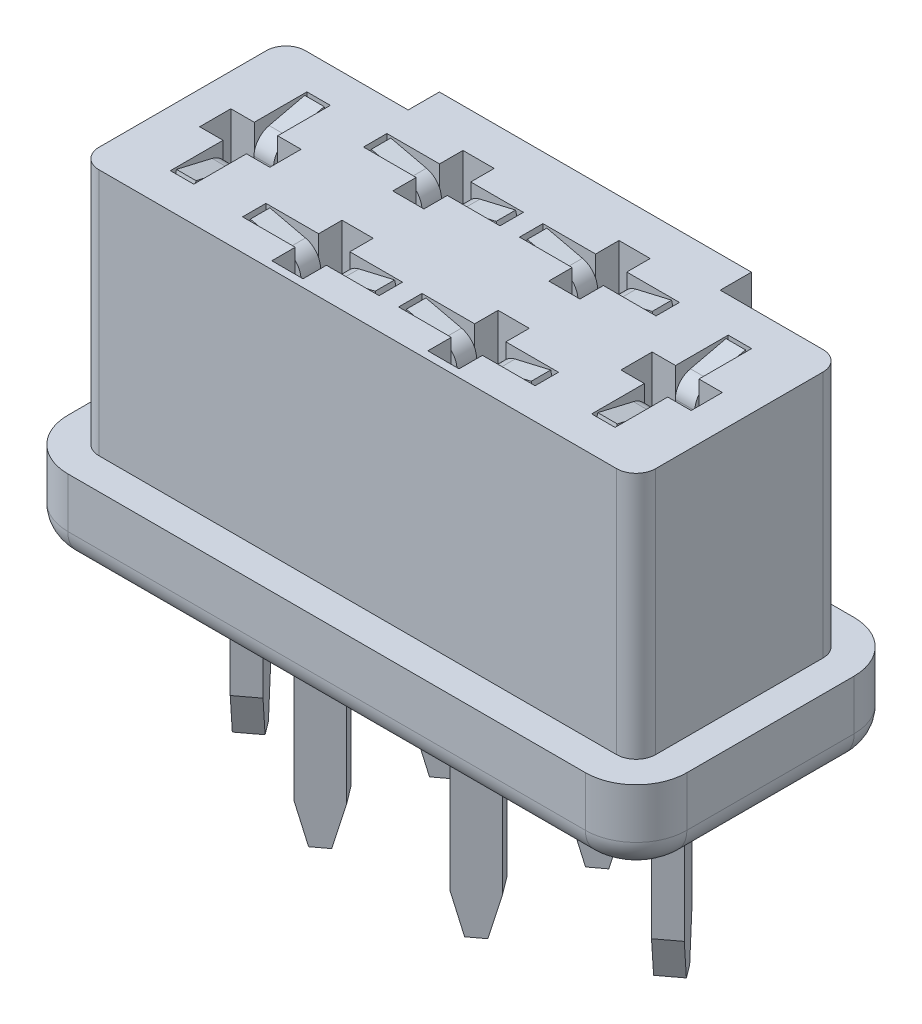
from build123d import *

# Parameters (mm, degrees)
SKETCH1_W              = 15.87
SKETCH1_H              = 6.89
BOSS_EXTRUDE1_DEPTH    = 8.38
FILLET1_R              = 1.3
FILLET2_R              = 0.75
SKETCH2_OUTSIDE_W      = 21.714
SKETCH2_OUTSIDE_H      = 12.734
CUT_EXTRUDE1_DEPTH     = 6.35
CUT_EXTRUDE2_DEPTH     = 3
BOSS_EXTRUDE2_DEPTH    = 4.69
CHAMFER1_SIZE          = 1
CHAMFER1_SIZE2         = 0.267949192
CHAMFER1_PART_2_SIZE   = 1
CHAMFER1_PART_2_SIZE2  = 0.267949192
CHAMFER1_PART_3_SIZE   = 1
CHAMFER1_PART_3_SIZE2  = 0.267949192
CHAMFER1_PART_4_SIZE   = 1
CHAMFER1_PART_4_SIZE2  = 0.267949192
CHAMFER1_PART_5_SIZE   = 1
CHAMFER1_PART_5_SIZE2  = 0.267949192
CHAMFER1_PART_6_SIZE   = 1
CHAMFER1_PART_6_SIZE2  = 0.267949192
CHAMFER1_PART_7_SIZE   = 1
CHAMFER1_PART_7_SIZE2  = 0.267949192
CHAMFER1_PART_8_SIZE   = 1
CHAMFER1_PART_8_SIZE2  = 0.267949192
CHAMFER1_PART_9_SIZE   = 1
CHAMFER1_PART_9_SIZE2  = 0.267949192
CHAMFER1_PART_10_SIZE  = 1
CHAMFER1_PART_10_SIZE2 = 0.267949192
CHAMFER1_PART_11_SIZE  = 1
CHAMFER1_PART_11_SIZE2 = 0.267949192
CHAMFER1_PART_12_SIZE  = 1
CHAMFER1_PART_12_SIZE2 = 0.267949192
BOSS_EXTRUDE3_DEPTH    = 0.25
MIRROR2_COPY_1_DEPTH   = 0.25
BOSS_EXTRUDE4_DEPTH    = 0.25
SKETCH8_W              = 0.769230769
SKETCH8_H              = 0.205128205
BOSS_EXTRUDE5_DEPTH    = 0.15


with BuildPart() as part:
    # Sketch1 → Boss-Extrude1 (new body)
    with BuildSketch(Plane(origin=(0, 0, 0), x_dir=(1, 0, 0), z_dir=(0, 1, 0))):
        Rectangle(SKETCH1_W, SKETCH1_H)
    extrude(amount=BOSS_EXTRUDE1_DEPTH)

    # Fillet1
    fillet1_edges = [part.edges().sort_by_distance(p)[0] for p in [
        (7.935, 4.19, 3.445),
        (-7.935, 4.19, 3.445),
        (-7.935, 4.19, -3.445),
        (7.935, 4.19, -3.445),
    ]]
    fillet(fillet1_edges, radius=FILLET1_R)

    # Fillet2
    fillet2_edges = [part.edges().sort_by_distance(p)[0] for p in [
        (0, 0, 3.445),
        (7.935, 0, 0),
        (-7.935, 0, 0),
        (0, 0, -3.445),
        (7.554238816, 0, 3.064238816),
        (7.554238816, 0, -3.064238816),
        (-7.554238816, 0, -3.064238816),
        (-7.554238816, 0, 3.064238816),
    ]]
    fillet(fillet2_edges, radius=FILLET2_R)

    # Sketch2 outside → Cut-Extrude1 (cut)
    with BuildSketch(Plane(origin=(0, 8.38, 0), x_dir=(1, 0, 0), z_dir=(0, 1, 0))):
        Rectangle(SKETCH2_OUTSIDE_W, SKETCH2_OUTSIDE_H)
        with BuildLine():
            Line((4, 2.645), (4, 3.445))
            Line((4, 3.445), (-4, 3.445))
            Line((-4, 3.445), (-4, 2.645))
            Line((-4, 2.645), (-6.635, 2.645))
            ThreePointArc((-6.635, 2.645), (-6.988553391, 2.498553391), (-7.135, 2.145))
            Line((-7.135, 2.145), (-7.135, -2.145))
            ThreePointArc((-7.135, -2.145), (-6.988553391, -2.498553391), (-6.635, -2.645))
            Line((-6.635, -2.645), (6.635, -2.645))
            ThreePointArc((6.635, -2.645), (6.988553391, -2.498553391), (7.135, -2.145))
            Line((7.135, -2.145), (7.135, 2.145))
            ThreePointArc((7.135, 2.145), (6.988553391, 2.498553391), (6.635, 2.645))
            Line((6.635, 2.645), (4, 2.645))
        make_face(mode=Mode.SUBTRACT)
    extrude(amount=-CUT_EXTRUDE1_DEPTH, mode=Mode.SUBTRACT)

    # Sketch3 → Cut-Extrude2 (cut)
    with BuildSketch(Plane(origin=(0, 8.38, 0), x_dir=(1, 0, 0), z_dir=(0, 1, 0))):
        Polygon((-2.4, -0.65), (-2.4, -1.25), (-3.75, -1.25), (-3.75, -1.85), (-2.4, -1.85), (-2.4, -2.45), (-1.6, -2.45), (-1.6, -1.85), (-0.25, -1.85), (-0.25, -1.25), (-1.6, -1.25), (-1.6, -0.65), align=None)
        Polygon((1.6, -0.65), (2.4, -0.65), (2.4, -1.25), (3.75, -1.25), (3.75, -1.85), (2.4, -1.85), (2.4, -2.45), (1.6, -2.45), (1.6, -1.85), (0.25, -1.85), (0.25, -1.25), (1.6, -1.25), align=None)
        Polygon((2.4, 0.65), (2.4, 1.25), (3.75, 1.25), (3.75, 1.85), (2.4, 1.85), (2.4, 2.45), (1.6, 2.45), (1.6, 1.85), (0.25, 1.85), (0.25, 1.25), (1.6, 1.25), (1.6, 0.65), align=None)
        Polygon((-1.6, 0.65), (-2.4, 0.65), (-2.4, 1.25), (-3.75, 1.25), (-3.75, 1.85), (-2.4, 1.85), (-2.4, 2.45), (-1.6, 2.45), (-1.6, 1.85), (-0.25, 1.85), (-0.25, 1.25), (-1.6, 1.25), align=None)
        Polygon((-5.7, 1.75), (-5.1, 1.75), (-5.1, 0.4), (-4.5, 0.4), (-4.5, -0.4), (-5.1, -0.4), (-5.1, -1.75), (-5.7, -1.75), (-5.7, -0.4), (-6.3, -0.4), (-6.3, 0.4), (-5.7, 0.4), align=None)
        Polygon((5.7, 0.4), (5.7, 1.75), (5.1, 1.75), (5.1, 0.4), (4.5, 0.4), (4.5, -0.4), (5.1, -0.4), (5.1, -1.75), (5.7, -1.75), (5.7, -0.4), (6.3, -0.4), (6.3, 0.4), align=None)
    extrude(amount=-CUT_EXTRUDE2_DEPTH, mode=Mode.SUBTRACT)

    # Sketch5 → Boss-Extrude2 (add)
    with BuildSketch(Plane.XZ):
        Polygon((-5.928, -0.204), (-5.352, 0.564), (-4.872, 0.204), (-5.448, -0.564), align=None)
        Polygon((-2.204, -1.022), (-1.436, -1.598), (-1.796, -2.078), (-2.564, -1.502), align=None)
        Polygon((-2.204, 2.078), (-1.436, 1.502), (-1.796, 1.022), (-2.564, 1.598), align=None)
        Polygon((1.796, 2.078), (2.564, 1.502), (2.204, 1.022), (1.436, 1.598), align=None)
        Polygon((1.796, -1.022), (2.564, -1.598), (2.204, -2.078), (1.436, -1.502), align=None)
        Polygon((4.872, -0.204), (5.448, 0.564), (5.928, 0.204), (5.352, -0.564), align=None)
    extrude(amount=BOSS_EXTRUDE2_DEPTH)

    # Chamfer1
    chamfer1_edges = [part.edges().sort_by_distance(p)[0] for p in [
        (-5.688, -4.69, -0.384),
    ]]
    chamfer1_side = [part.faces().sort_by_distance(p)[0] for p in [
        (-5.688, -2.345, -0.384),
    ]]
    chamfer(chamfer1_edges, length=CHAMFER1_SIZE, length2=CHAMFER1_SIZE2, reference=chamfer1_side[0])

    # Chamfer1 part 2
    chamfer1_part_2_edges = [part.edges().sort_by_distance(p)[0] for p in [
        (-5.112, -4.69, 0.384),
    ]]
    chamfer1_part_2_side = [part.faces().sort_by_distance(p)[0] for p in [
        (-5.112, -2.345, 0.384),
    ]]
    chamfer(chamfer1_part_2_edges, length=CHAMFER1_PART_2_SIZE, length2=CHAMFER1_PART_2_SIZE2, reference=chamfer1_part_2_side[0])

    # Chamfer1 part 3
    chamfer1_part_3_edges = [part.edges().sort_by_distance(p)[0] for p in [
        (-2.384, -4.69, -1.262),
    ]]
    chamfer1_part_3_side = [part.faces().sort_by_distance(p)[0] for p in [
        (-2.384, -2.345, -1.262),
    ]]
    chamfer(chamfer1_part_3_edges, length=CHAMFER1_PART_3_SIZE, length2=CHAMFER1_PART_3_SIZE2, reference=chamfer1_part_3_side[0])

    # Chamfer1 part 4
    chamfer1_part_4_edges = [part.edges().sort_by_distance(p)[0] for p in [
        (-1.616, -4.69, -1.838),
    ]]
    chamfer1_part_4_side = [part.faces().sort_by_distance(p)[0] for p in [
        (-1.616, -2.345, -1.838),
    ]]
    chamfer(chamfer1_part_4_edges, length=CHAMFER1_PART_4_SIZE, length2=CHAMFER1_PART_4_SIZE2, reference=chamfer1_part_4_side[0])

    # Chamfer1 part 5
    chamfer1_part_5_edges = [part.edges().sort_by_distance(p)[0] for p in [
        (-2.384, -4.69, 1.838),
    ]]
    chamfer1_part_5_side = [part.faces().sort_by_distance(p)[0] for p in [
        (-2.384, -2.345, 1.838),
    ]]
    chamfer(chamfer1_part_5_edges, length=CHAMFER1_PART_5_SIZE, length2=CHAMFER1_PART_5_SIZE2, reference=chamfer1_part_5_side[0])

    # Chamfer1 part 6
    chamfer1_part_6_edges = [part.edges().sort_by_distance(p)[0] for p in [
        (-1.616, -4.69, 1.262),
    ]]
    chamfer1_part_6_side = [part.faces().sort_by_distance(p)[0] for p in [
        (-1.616, -2.345, 1.262),
    ]]
    chamfer(chamfer1_part_6_edges, length=CHAMFER1_PART_6_SIZE, length2=CHAMFER1_PART_6_SIZE2, reference=chamfer1_part_6_side[0])

    # Chamfer1 part 7
    chamfer1_part_7_edges = [part.edges().sort_by_distance(p)[0] for p in [
        (1.616, -4.69, 1.838),
    ]]
    chamfer1_part_7_side = [part.faces().sort_by_distance(p)[0] for p in [
        (1.616, -2.345, 1.838),
    ]]
    chamfer(chamfer1_part_7_edges, length=CHAMFER1_PART_7_SIZE, length2=CHAMFER1_PART_7_SIZE2, reference=chamfer1_part_7_side[0])

    # Chamfer1 part 8
    chamfer1_part_8_edges = [part.edges().sort_by_distance(p)[0] for p in [
        (2.384, -4.69, 1.262),
    ]]
    chamfer1_part_8_side = [part.faces().sort_by_distance(p)[0] for p in [
        (2.384, -2.345, 1.262),
    ]]
    chamfer(chamfer1_part_8_edges, length=CHAMFER1_PART_8_SIZE, length2=CHAMFER1_PART_8_SIZE2, reference=chamfer1_part_8_side[0])

    # Chamfer1 part 9
    chamfer1_part_9_edges = [part.edges().sort_by_distance(p)[0] for p in [
        (1.616, -4.69, -1.262),
    ]]
    chamfer1_part_9_side = [part.faces().sort_by_distance(p)[0] for p in [
        (1.616, -2.345, -1.262),
    ]]
    chamfer(chamfer1_part_9_edges, length=CHAMFER1_PART_9_SIZE, length2=CHAMFER1_PART_9_SIZE2, reference=chamfer1_part_9_side[0])

    # Chamfer1 part 10
    chamfer1_part_10_edges = [part.edges().sort_by_distance(p)[0] for p in [
        (2.384, -4.69, -1.838),
    ]]
    chamfer1_part_10_side = [part.faces().sort_by_distance(p)[0] for p in [
        (2.384, -2.345, -1.838),
    ]]
    chamfer(chamfer1_part_10_edges, length=CHAMFER1_PART_10_SIZE, length2=CHAMFER1_PART_10_SIZE2, reference=chamfer1_part_10_side[0])

    # Chamfer1 part 11
    chamfer1_part_11_edges = [part.edges().sort_by_distance(p)[0] for p in [
        (5.112, -4.69, -0.384),
    ]]
    chamfer1_part_11_side = [part.faces().sort_by_distance(p)[0] for p in [
        (5.112, -2.345, -0.384),
    ]]
    chamfer(chamfer1_part_11_edges, length=CHAMFER1_PART_11_SIZE, length2=CHAMFER1_PART_11_SIZE2, reference=chamfer1_part_11_side[0])

    # Chamfer1 part 12
    chamfer1_part_12_edges = [part.edges().sort_by_distance(p)[0] for p in [
        (5.688, -4.69, 0.384),
    ]]
    chamfer1_part_12_side = [part.faces().sort_by_distance(p)[0] for p in [
        (5.688, -2.345, 0.384),
    ]]
    chamfer(chamfer1_part_12_edges, length=CHAMFER1_PART_12_SIZE, length2=CHAMFER1_PART_12_SIZE2, reference=chamfer1_part_12_side[0])

    # Sketch6 → Boss-Extrude3 (add, symmetric)
    with BuildSketch(Plane(origin=(0, 0, -1.55), x_dir=(-1, 0, 0), z_dir=(0, 0, -1))):
        with BuildLine():
            Line((-2.3, 5.68), (-1.7, 5.68))
            Line((-1.7, 5.68), (-1.7, 7.68))
            ThreePointArc((-1.7, 7.68), (-1.591652135, 7.990819249), (-1.313565578, 8.166932089))
            Line((-1.313565578, 8.166932089), (-0.4, 8.38))
            Line((-0.4, 8.38), (-0.331860653, 8.087840746))
            Line((-0.331860653, 8.087840746), (-1.245426231, 7.874772836))
            ThreePointArc((-1.245426231, 7.874772836), (-1.356660854, 7.8043277), (-1.4, 7.68))
            Line((-1.4, 7.68), (-1.4, 5.38))
            Line((-1.4, 5.38), (-2.6, 5.38))
            Line((-2.6, 5.38), (-2.6, 7.68))
            ThreePointArc((-2.6, 7.68), (-2.643339146, 7.8043277), (-2.754573769, 7.874772836))
            Line((-2.754573769, 7.874772836), (-3.668139347, 8.087840746))
            Line((-3.668139347, 8.087840746), (-3.6, 8.38))
            Line((-3.6, 8.38), (-2.686434422, 8.166932089))
            ThreePointArc((-2.686434422, 8.166932089), (-2.408347865, 7.990819249), (-2.3, 7.68))
            Line((-2.3, 7.68), (-2.3, 5.68))
        make_face()
    boss_extrude3 = extrude(amount=BOSS_EXTRUDE3_DEPTH, both=True)

    # Mirror1: Boss-Extrude3 across plane
    add(boss_extrude3.mirror(Plane(origin=(0, 0, 0), x_dir=(0, 0, 1), z_dir=(1, 0, 0))))

    # Mirror2: Boss-Extrude3 across plane
    add(boss_extrude3.mirror(Plane.XY))

    # Mirror2 copy 1 sketch → Mirror2 copy 1 (add, symmetric)
    with BuildSketch(Plane.XY.offset(1.55)):
        with BuildLine():
            Line((-2.3, 5.68), (-1.7, 5.68))
            Line((-1.7, 5.68), (-1.7, 7.68))
            ThreePointArc((-1.7, 7.68), (-1.591652135, 7.990819249), (-1.313565578, 8.166932089))
            Line((-1.313565578, 8.166932089), (-0.4, 8.38))
            Line((-0.4, 8.38), (-0.331860653, 8.087840746))
            Line((-0.331860653, 8.087840746), (-1.245426231, 7.874772836))
            ThreePointArc((-1.245426231, 7.874772836), (-1.356660854, 7.8043277), (-1.4, 7.68))
            Line((-1.4, 7.68), (-1.4, 5.38))
            Line((-1.4, 5.38), (-2.6, 5.38))
            Line((-2.6, 5.38), (-2.6, 7.68))
            ThreePointArc((-2.6, 7.68), (-2.643339146, 7.8043277), (-2.754573769, 7.874772836))
            Line((-2.754573769, 7.874772836), (-3.668139347, 8.087840746))
            Line((-3.668139347, 8.087840746), (-3.6, 8.38))
            Line((-3.6, 8.38), (-2.686434422, 8.166932089))
            ThreePointArc((-2.686434422, 8.166932089), (-2.408347865, 7.990819249), (-2.3, 7.68))
            Line((-2.3, 7.68), (-2.3, 5.68))
        make_face()
    extrude(amount=MIRROR2_COPY_1_DEPTH, both=True)

    # Sketch7 → Boss-Extrude4 (add, symmetric)
    with BuildSketch(Plane.ZY.offset(5.4)):
        with BuildLine():
            Line((-0.34356411, 5.68), (0.34356411, 5.68))
            Line((0.34356411, 5.68), (0.34356411, 7.68))
            ThreePointArc((0.34356411, 7.68), (0.451911976, 7.990819249), (0.729998532, 8.166932089))
            Line((0.729998532, 8.166932089), (1.64356411, 8.38))
            Line((1.64356411, 8.38), (1.711703457, 8.087840746))
            Line((1.711703457, 8.087840746), (0.798137879, 7.874772836))
            ThreePointArc((0.798137879, 7.874772836), (0.686903256, 7.8043277), (0.64356411, 7.68))
            Line((0.64356411, 7.68), (0.64356411, 5.38))
            Line((0.64356411, 5.38), (-0.64356411, 5.38))
            Line((-0.64356411, 5.38), (-0.64356411, 7.68))
            ThreePointArc((-0.64356411, 7.68), (-0.686903256, 7.8043277), (-0.798137879, 7.874772836))
            Line((-0.798137879, 7.874772836), (-1.711703457, 8.087840746))
            Line((-1.711703457, 8.087840746), (-1.64356411, 8.38))
            Line((-1.64356411, 8.38), (-0.729998532, 8.166932089))
            ThreePointArc((-0.729998532, 8.166932089), (-0.451911976, 7.990819249), (-0.34356411, 7.68))
            Line((-0.34356411, 7.68), (-0.34356411, 5.68))
        make_face()
    boss_extrude4 = extrude(amount=BOSS_EXTRUDE4_DEPTH, both=True)

    # Mirror3: Boss-Extrude4 across plane
    add(boss_extrude4.mirror(Plane(origin=(0, 0, 0), x_dir=(0, 0, 1), z_dir=(1, 0, 0))))

    # Sketch8 → Boss-Extrude5 (add)
    with BuildSketch(Plane.XZ):
        with Locations((-5.483370513, 1.487427858)):
            Rectangle(SKETCH8_W, SKETCH8_H)
        Polygon((5.442706084, 1.533944278), (5.442706084, 1.976251971), (5.577321469, 1.976251971), (5.577321469, 1.533944278), (6.019629161, 1.533944278), (6.019629161, 1.399328894), (5.577321469, 1.399328894), (5.577321469, 0.957021201), (5.442706084, 0.957021201), (5.442706084, 1.399328894), (5.000398392, 1.399328894), (5.000398392, 1.533944278), align=None)
        Polygon((-0.685537905, 2.086538462), (0.814462095, 1.888521635), (0.814462095, 1.869290865), (-0.416307136, 1.25), (0.814462095, 0.632211538), (0.814462095, 0.612680288), (-0.685537905, 0.413461538), (-0.685537905, 0.548677885), (0.393789018, 0.692307692), (-0.685537905, 1.233774038), (-0.685537905, 1.264122596), (0.396192864, 1.807692308), (-0.685537905, 1.951021635), align=None)
        with BuildLine():
            Line((0.814462095, 0.105769231), (0.814462095, -0.188401442))
            add(Edge.make_bspline(
                [(0.814462095, -0.188401442), (0.814439854, -0.208634688), (0.814397239, -0.247402485), (0.813105205, -0.302994651), (0.81137948, -0.353484536), (0.80898724, -0.398763271), (0.80616013, -0.43897017), (0.80219497, -0.473923299), (0.798054843, -0.503897394), (0.793845669, -0.521857301), (0.791926037, -0.530048077)],
                knots=[0, 0, 0, 0, 6.0698e-05, 0.0001163, 0.000166813, 0.000212249, 0.000252326, 0.000287698, 0.000317785, 0.000343012, 0.000343012, 0.000343012, 0.000343012], degree=3))
            add(Edge.make_bspline(
                [(0.791926037, -0.530048077), (0.789088084, -0.540416759), (0.783479051, -0.560909797), (0.772244232, -0.590438462), (0.758924663, -0.618534282), (0.743737948, -0.645285804), (0.72606272, -0.670393235), (0.7064581, -0.694177969), (0.684934872, -0.716776426), (0.661075793, -0.737420944), (0.635760539, -0.756426873), (0.608425328, -0.772731078), (0.579665098, -0.786522282), (0.549185311, -0.797785496), (0.517171213, -0.806349883), (0.483529347, -0.812677522), (0.448375308, -0.816726024), (0.424349139, -0.817111475), (0.412118345, -0.817307692)],
                knots=[0, 0, 0, 0, 3.2236e-05, 6.3712e-05, 9.4626e-05, 0.000125448, 0.000155874, 0.000186614, 0.000217854, 0.000249372, 0.000281163, 0.000312701, 0.000344688, 0.000376727, 0.000410038, 0.000443983, 0.000479356, 0.000516034, 0.000516034, 0.000516034, 0.000516034], degree=3))
            add(Edge.make_bspline(
                [(0.412118345, -0.817307692), (0.399785012, -0.817127082), (0.375654013, -0.816773705), (0.34035139, -0.81253244), (0.306614937, -0.8068195), (0.274519458, -0.798035049), (0.244255557, -0.786529761), (0.215360743, -0.773033167), (0.188326598, -0.756754511), (0.163054976, -0.738049584), (0.139522156, -0.717241758), (0.117898673, -0.69441907), (0.098311099, -0.669673659), (0.080715524, -0.643084167), (0.065519975, -0.614391375), (0.051909702, -0.584030452), (0.040479247, -0.551737502), (0.034466364, -0.52939071), (0.031409211, -0.518028846)],
                knots=[0, 0, 0, 0, 3.6979e-05, 7.2351e-05, 0.000106537, 0.000139559, 0.000171984, 0.000203571, 0.000235108, 0.000266479, 0.000297771, 0.000329229, 0.00036067, 0.000392339, 0.000424738, 0.000457963, 0.000492081, 0.000527371, 0.000527371, 0.000527371, 0.000527371], degree=3))
            add(Edge.make_bspline(
                [(0.031409211, -0.518028846), (0.02941079, -0.508631417), (0.025031135, -0.488036406), (0.020141797, -0.454118096), (0.015968539, -0.414627216), (0.01283948, -0.369617668), (0.010160751, -0.319129851), (0.008031568, -0.263136455), (0.006861631, -0.201527565), (0.006801291, -0.158554175), (0.006769787, -0.136117788)],
                knots=[0, 0, 0, 0, 2.8816e-05, 6.3153e-05, 0.00010274, 0.000147933, 0.000198486, 0.000254415, 0.000316026, 0.000383334, 0.000383334, 0.000383334, 0.000383334], degree=3))
            Line((0.006769787, -0.136117788), (0.006769787, -0.028846154))
            Line((0.006769787, -0.028846154), (-0.685537905, -0.028846154))
            Line((-0.685537905, -0.028846154), (-0.685537905, 0.105769231))
            Line((-0.685537905, 0.105769231), (0.814462095, 0.105769231))
        make_face()
        with BuildLine():
            Line((0.660615941, -0.028846154), (0.160615941, -0.028846154))
            Line((0.160615941, -0.028846154), (0.157310653, -0.291466346))
            add(Edge.make_bspline(
                [(0.157310653, -0.291466346), (0.157302634, -0.304289297), (0.157287154, -0.329043739), (0.159018542, -0.364900309), (0.160928379, -0.398081594), (0.163919265, -0.428659652), (0.16786004, -0.456400803), (0.172149497, -0.481661374), (0.177960858, -0.504071563), (0.186063877, -0.530332201), (0.199614387, -0.559495242), (0.219790106, -0.591010898), (0.244801561, -0.618152302), (0.273309526, -0.641482376), (0.305138776, -0.659563122), (0.338927011, -0.673162148), (0.37469549, -0.681083502), (0.399159975, -0.682152393), (0.411517384, -0.682692308)],
                knots=[0, 0, 0, 0, 3.8463e-05, 7.4251e-05, 0.000107671, 0.000138168, 0.000166384, 0.000191728, 0.000214976, 0.000235788, 0.000274109, 0.000311031, 0.000347615, 0.00038436, 0.000421108, 0.000456987, 0.000493294, 0.000530352, 0.000530352, 0.000530352, 0.000530352], degree=3))
            add(Edge.make_bspline(
                [(0.411517384, -0.682692308), (0.423575809, -0.68214951), (0.447546467, -0.681070496), (0.482694048, -0.673099665), (0.516123802, -0.659589668), (0.547561195, -0.641359858), (0.57595249, -0.618699665), (0.600399476, -0.59215974), (0.620319477, -0.562282012), (0.633087986, -0.534474932), (0.640897047, -0.509790901), (0.646358512, -0.488348102), (0.650719679, -0.464137981), (0.654250835, -0.437151738), (0.657273765, -0.407598825), (0.659324893, -0.375225256), (0.660525519, -0.340153696), (0.660585071, -0.315806309), (0.660615941, -0.303185096)],
                knots=[0, 0, 0, 0, 3.6159e-05, 7.188e-05, 0.000107479, 0.000143967, 0.000180523, 0.000216037, 0.000251789, 0.000287823, 0.000307398, 0.000329407, 0.00035416, 0.000381145, 0.000411044, 0.000443264, 0.000478441, 0.000516303, 0.000516303, 0.000516303, 0.000516303], degree=3))
            Line((0.660615941, -0.303185096), (0.660615941, -0.028846154))
        make_face(mode=Mode.SUBTRACT)
        Polygon((0.814462095, -1.019230769), (0.814462095, -1.174579327), (0.200880364, -1.567307692), (0.814462095, -1.960036058), (0.814462095, -2.115384615), (0.079486134, -1.645132212), (-0.685537905, -2.134615385), (-0.685537905, -1.979266827), (-0.041908097, -1.567307692), (-0.685537905, -1.155348558), (-0.685537905, -1), (0.079486134, -1.489783654), align=None)
    extrude(amount=BOSS_EXTRUDE5_DEPTH)


solid = part.part
